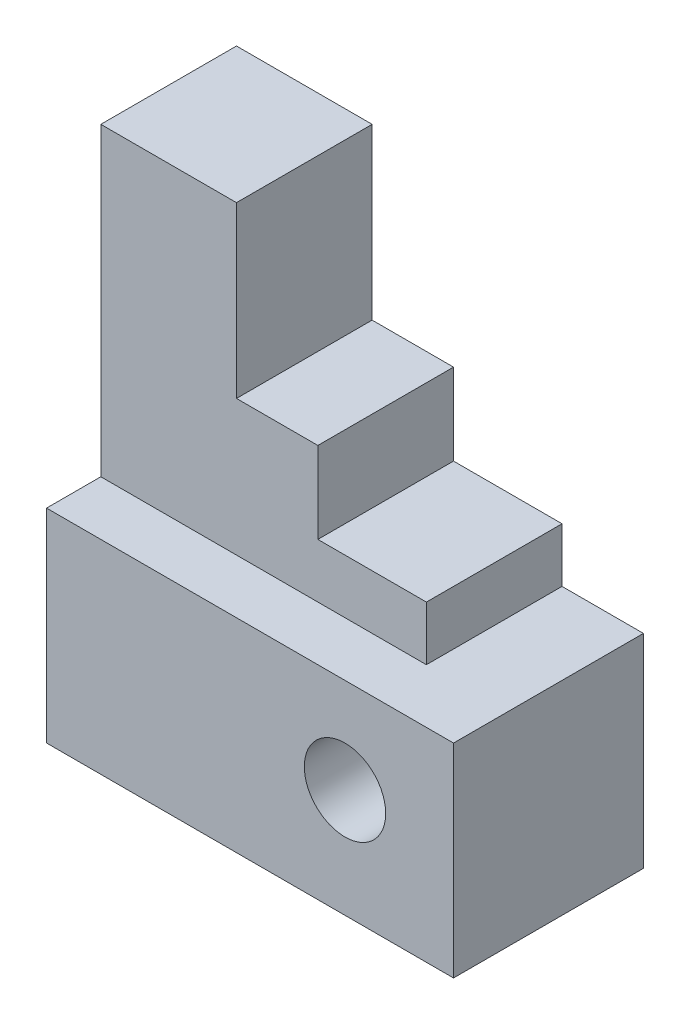
from build123d import *

# Parameters (mm, degrees)
SKETCH1_R           = 6
BOSS_EXTRUDE1_DEPTH = 28
BOSS_EXTRUDE2_DEPTH = 20


with BuildPart() as part:
    # Sketch1 → Boss-Extrude1 (new body)
    with BuildSketch(Plane.XY):
        Polygon((48, 30), (0, 30), (0, 0), (60, 0), (60, 30), align=None)
        with Locations((44, 16)):
            Circle(SKETCH1_R, mode=Mode.SUBTRACT)
    extrude(amount=BOSS_EXTRUDE1_DEPTH)

    # Sketch1_3 → Boss-Extrude2 (add)
    with BuildSketch(Plane.XY):
        Polygon((0, 75), (0, 30), (48, 30), (48, 38), (32, 38), (32, 50), (20, 50), (20, 75), align=None)
    extrude(amount=BOSS_EXTRUDE2_DEPTH)


solid = part.part
